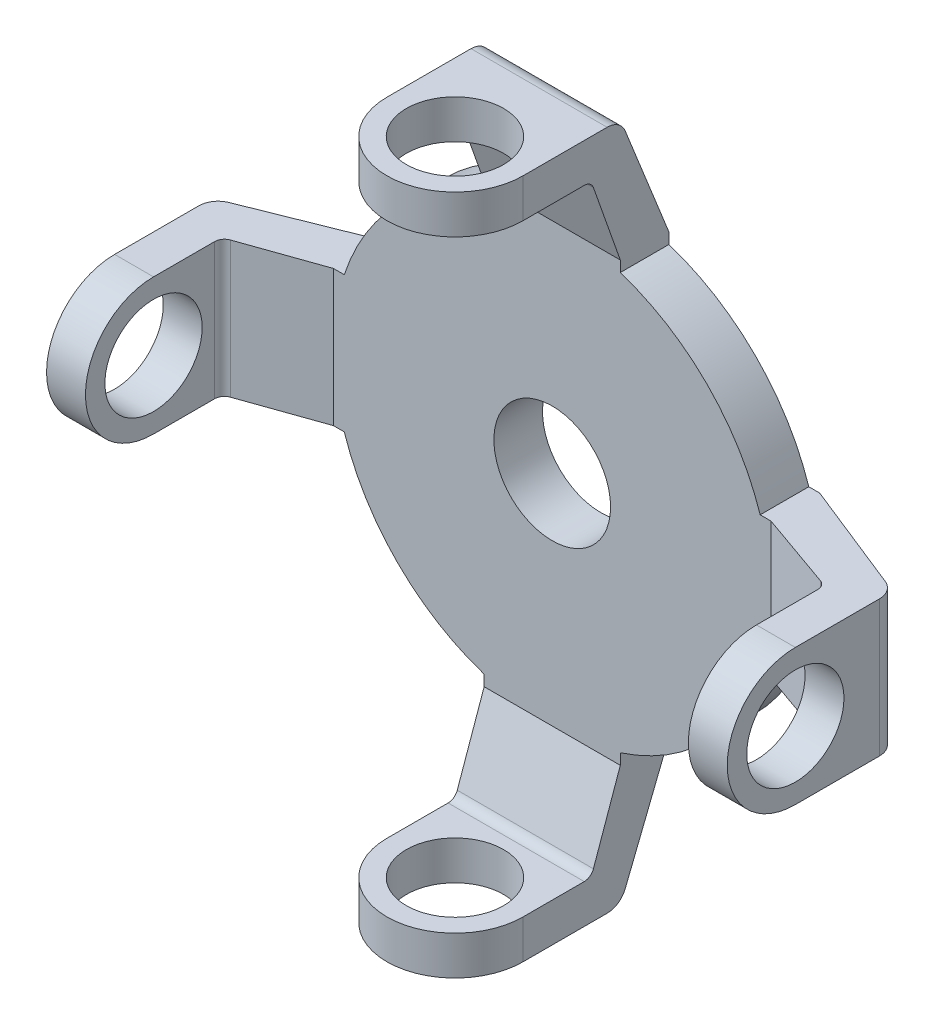
from build123d import *

# Parameters (mm, degrees)
SKETCH3_R                = 22.5
SKETCH3_R_2              = 6
BOSS_EXTRUDE3_DEPTH      = 5
SKETCH4_R                = 15
SKETCH4_R_2              = 13
BOSS_EXTRUDE4_DEPTH      = 2.75
SKETCH10_R               = 7
SKETCH10_R_2             = 5
BOSS_EXTRUDE5_DEPTH      = 2
BOSS_EXTRUDE6_REACH      = 45.9
BOSS_EXTRUDE6_END_RADIUS = 7
SKETCH11_W               = 4
SKETCH11_H               = 14
BOSS_EXTRUDE7_DEPTH      = 14
SKETCH15_W               = 5
SKETCH15_H               = 14
BOSS_EXTRUDE8_DEPTH      = 1.116595
FILLET1_R                = 1
CIRPATTERN4_COUNT        = 4
FILLET1_OF_CIRPATTERN4_R = 1


with BuildPart() as part:
    # Sketch3 → Boss-Extrude3 (new body)
    with BuildSketch(Plane.XY):
        Circle(SKETCH3_R)
        Circle(SKETCH3_R_2, mode=Mode.SUBTRACT)
    extrude(amount=BOSS_EXTRUDE3_DEPTH)

    # Sketch4 → Boss-Extrude4 (add)
    with BuildSketch(Plane(origin=(0, 0, 0), x_dir=(-1, 0, 0), z_dir=(0, 0, -1))):
        with Locations(Location((0, 0, 0), (0, 0, 180))):
            Circle(SKETCH4_R)
        Circle(SKETCH4_R_2, mode=Mode.SUBTRACT)
    extrude(amount=BOSS_EXTRUDE4_DEPTH)

    # Sketch6 → Revolve1 (revolve)
    with BuildSketch(Plane(origin=(0, 0, 0), x_dir=(0, 0, -1), z_dir=(1, 0, 0)), mode=Mode.PRIVATE) as revolve1_sk:
        Polygon((0, 22.5), (0, 15), (2.75, 15), align=None)
    revolve(revolve1_sk.sketch.rotate(Axis((0, 0, 0), (0, 0, -1)), 90), axis=Axis((0, 0, 0), (0, 0, -1)))



with BuildPart() as body_2:
    # Sketch10 → Boss-Extrude5 (new, symmetric)
    with BuildSketch(Plane(origin=(33, 0, 0), x_dir=(0, 0, -1), z_dir=(1, 0, 0))):
        with Locations((-15, 0)):
            Circle(SKETCH10_R)
        with Locations((-15, 0)):
            Circle(SKETCH10_R_2, mode=Mode.SUBTRACT)
    boss_extrude5 = extrude(amount=BOSS_EXTRUDE5_DEPTH, both=True)

    # Boss-Extrude6: up to this cylinder (the profile starts outside it)
    boss_extrude6_end = Plane(origin=(33, 0, 15), z_dir=(-1, 0, 0)) * Cylinder(BOSS_EXTRUDE6_END_RADIUS, 106.8, mode=Mode.PRIVATE)
    # Sketch11 → Boss-Extrude6 (add, up to the surface)
    with BuildSketch(Plane(origin=(0, 0, 8), x_dir=(-1, 0, 0), z_dir=(0, 0, -1)), mode=Mode.PRIVATE) as boss_extrude6_sk1:
        with Locations((-33, 0)):
            Rectangle(SKETCH11_W, SKETCH11_H)
    boss_extrude6_tool1 = extrude(boss_extrude6_sk1.sketch, amount=-BOSS_EXTRUDE6_REACH, mode=Mode.PRIVATE) - boss_extrude6_end
    boss_extrude6 = boss_extrude6_tool1.solids().sort_by_distance((33, 0, 8))[0] + boss_extrude6_tool1.solids().sort_by_distance((33, 0, 8))[1]
    add(boss_extrude6)

    # Sketch12 → Boss-Extrude7 (add)
    with BuildSketch(Plane(origin=(0, -7, 0), x_dir=(1, 0, 0), z_dir=(0, 1, 0))):
        with BuildLine():
            Line((31, -8), (22.5, -5))
            Line((22.5, -5), (22.5, 0))
            Line((22.5, 0), (33.742781353, -4.497112541))
            ThreePointArc((33.742781353, -4.497112541), (34.656134461, -5.232808304), (35, -6.354065923))
            Line((35, -6.354065923), (35, -8))
            Line((35, -8), (31, -8))
        make_face()
    boss_extrude7 = extrude(amount=BOSS_EXTRUDE7_DEPTH)


with BuildPart() as part_1:
    add(part.part)

    add(body_2.part)  # Boss-Extrude8 merges body 2
    # Sketch15 → Boss-Extrude8 (add)
    with BuildSketch(Plane.ZY.offset(-22.5)):
        with Locations((2.5, 0)):
            Rectangle(SKETCH15_W, SKETCH15_H)
    boss_extrude8 = extrude(amount=BOSS_EXTRUDE8_DEPTH)

    # Fillet1
    fillet1_edges = [part_1.edges().sort_by_distance(p)[0] for p in [
        (31, 0, 8),
    ]]
    fillet(fillet1_edges, radius=FILLET1_R)

    # CirPattern4: Boss-Extrude5, Boss-Extrude6, Boss-Extrude7, Boss-Extrude8 ×4 about axis
    cirpattern4_axis = Axis((0, 0, 0), (0, 0, 1))
    add([boss_extrude5.rotate(cirpattern4_axis, i * 360 / CIRPATTERN4_COUNT) for i in range(1, CIRPATTERN4_COUNT)])
    add([boss_extrude6.rotate(cirpattern4_axis, i * 360 / CIRPATTERN4_COUNT) for i in range(1, CIRPATTERN4_COUNT)])
    add([boss_extrude7.rotate(cirpattern4_axis, i * 360 / CIRPATTERN4_COUNT) for i in range(1, CIRPATTERN4_COUNT)])
    add([boss_extrude8.rotate(cirpattern4_axis, i * 360 / CIRPATTERN4_COUNT) for i in range(1, CIRPATTERN4_COUNT)])

    # Fillet1 of CirPattern4
    fillet1_of_cirpattern4_edges = [part_1.edges().sort_by_distance(p)[0] for p in [
        (0, 31, 8),
        (-31, 0, 8),
        (0, -31, 8),
    ]]
    fillet(fillet1_of_cirpattern4_edges, radius=FILLET1_OF_CIRPATTERN4_R)


solid = part_1.part
